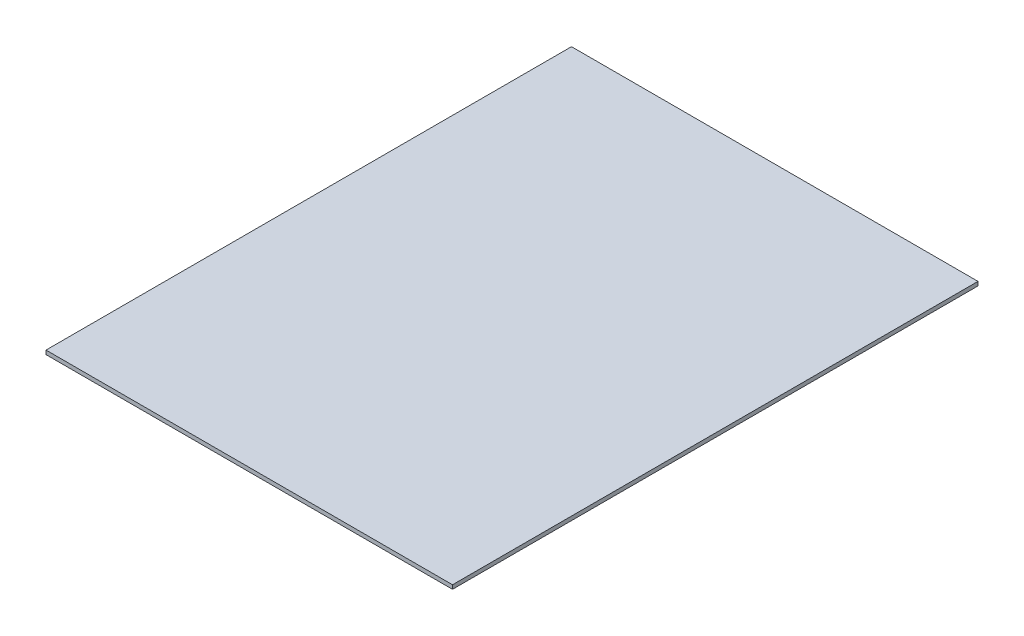
from build123d import *

# Parameters (mm, degrees)
SKETCH1_W           = 520.7
SKETCH1_H           = 673.1
BOSS_EXTRUDE1_DEPTH = 5.08


with BuildPart() as part:
    # Sketch1 → Boss-Extrude1 (new body)
    with BuildSketch(Plane(origin=(0, 0, 0), x_dir=(1, 0, 0), z_dir=(0, 1, 0))):
        with Locations((260.35, -336.55)):
            Rectangle(SKETCH1_W, SKETCH1_H)
    extrude(amount=BOSS_EXTRUDE1_DEPTH)


solid = part.part
